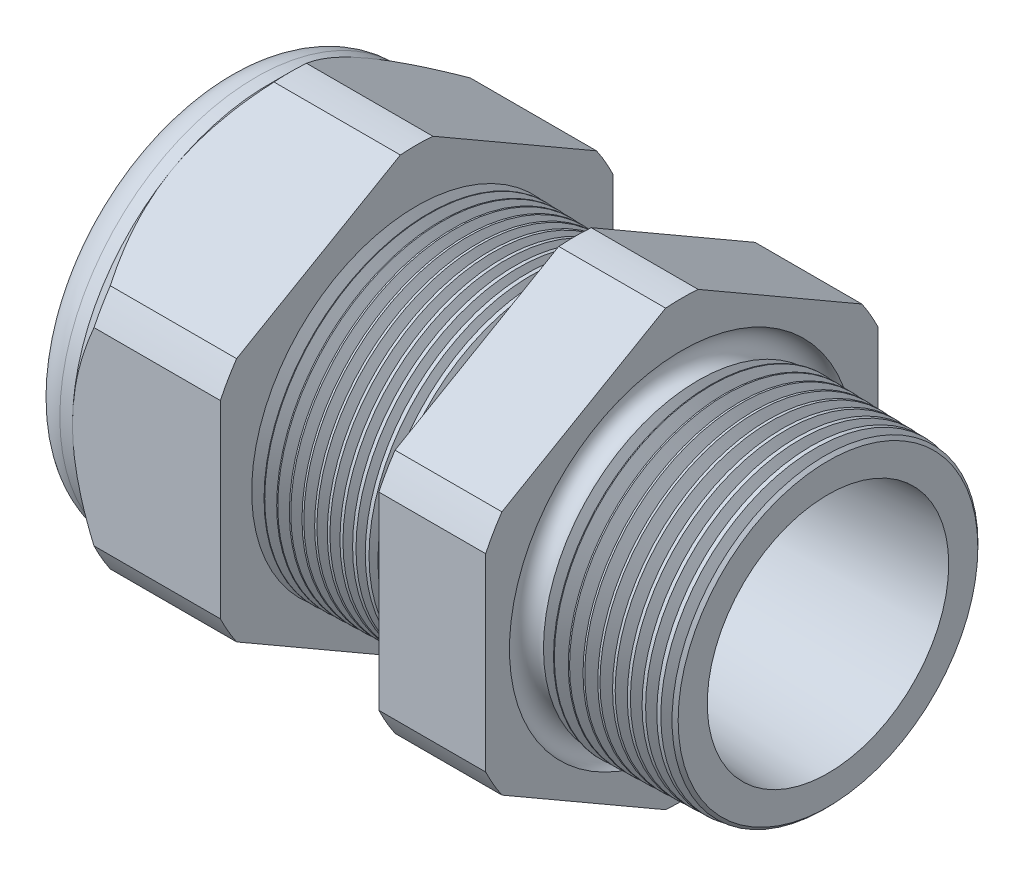
from build123d import *

# Parameters (mm, degrees)
SKETCH12_OUTSIDE_W = 65.136
SKETCH12_OUTSIDE_H = 65.136
CUT_EXTRUDE2_DEPTH = 35.03
FILLET4_R          = 2.032
SKETCH19_OUTSIDE_W = 40.13
SKETCH19_OUTSIDE_H = 42.756
SKETCH19_OUTSIDE_R = 11.938
CUT_EXTRUDE3_DEPTH = 1.999996
CUT_EXTRUDE3_DRAFT = -45
CHAMFER1_SIZE      = 0.260919487
CHAMFER1_SIZE2     = 0.254
SKETCH21_R         = 5.969
PLUG_DEPTH         = 6.35
SKETCH22_R         = 5.715
CUT_EXTRUDE4_DEPTH = 0.508
SKETCH27_R         = 2.54
PLUGHOLES_DEPTH    = 37.322
CIRPATTERN1_COUNT  = 3
LPATTERN1_COUNT    = 13
LPATTERN1_PITCH    = 0.762
LPATTERN2_COUNT    = 10
LPATTERN2_PITCH    = 0.889
SKETCH32_R         = 0.889


with BuildPart() as part:
    # Sketch10 → Revolve2 (revolve)
    with BuildSketch(Plane.XY, mode=Mode.PRIVATE) as revolve2_sk:
        Polygon((-35.814, 5.969), (-24.014, 5.969), (1.016, 7.345566383), (1.016, 9.377566383), (-7.874, 9.610359226), (-7.874, 23.876), (-14.374, 23.876), (-14.374, 9.780567716), (-24.014, 10.033), (-24.014, 23.876), (-33.014, 23.876), (-33.014, 11.938), (-35.814, 11.938), align=None)
    revolve(revolve2_sk.sketch.rotate(Axis((0, 0, 0), (-1, 0, 0)), 90), axis=Axis((0, 0, 0), (-1, 0, 0)))  # turned: the seam where the file's is

    # Sketch12 outside → Cut-Extrude2 (cut, through all)
    with BuildSketch(Plane.ZY.offset(33.014)):
        Rectangle(SKETCH12_OUTSIDE_W, SKETCH12_OUTSIDE_H)
        with BuildLine():
            Line((-0.98819228, 13.214281948), (-10.94980772, 7.462940592))
            ThreePointArc((-10.94980772, 7.462940592), (-11.47585851, 6.62559), (-11.938, 5.751341356))
            Line((-11.938, 5.751341356), (-11.938, -5.751341356))
            ThreePointArc((-11.938, -5.751341356), (-11.47585851, -6.62559), (-10.94980772, -7.462940592))
            Line((-10.94980772, -7.462940592), (-0.98819228, -13.214281948))
            ThreePointArc((-0.98819228, -13.214281948), (0, -13.25118), (0.98819228, -13.214281948))
            Line((0.98819228, -13.214281948), (10.94980772, -7.462940592))
            ThreePointArc((10.94980772, -7.462940592), (11.47585851, -6.62559), (11.938, -5.751341356))
            Line((11.938, -5.751341356), (11.938, 5.751341356))
            ThreePointArc((11.938, 5.751341356), (11.47585851, 6.62559), (10.94980772, 7.462940592))
            Line((10.94980772, 7.462940592), (0.98819228, 13.214281948))
            ThreePointArc((0.98819228, 13.214281948), (0, 13.25118), (-0.98819228, 13.214281948))
        make_face(mode=Mode.SUBTRACT)
    extrude(amount=-CUT_EXTRUDE2_DEPTH, mode=Mode.SUBTRACT)

    # Fillet4
    fillet4_edges = [part.edges().sort_by_distance(p)[0] for p in [
        (-35.814, 0, 11.938),
    ]]
    fillet(fillet4_edges, radius=FILLET4_R)


with BuildPart() as cut_extrude3_tool:
    # Sketch19 outside → Cut-Extrude3 (with draft: the straight prism first)
    with BuildSketch(Plane.ZY.offset(33.014)):
        Rectangle(SKETCH19_OUTSIDE_W, SKETCH19_OUTSIDE_H)
        Circle(SKETCH19_OUTSIDE_R, mode=Mode.SUBTRACT)
    extrude(amount=-CUT_EXTRUDE3_DEPTH)
    # Cut-Extrude3: the draft: its side faces are tilted about the plane it starts from
    cut_extrude3_sides = [cut_extrude3_tool.faces().sort_by_distance(p)[0] for p in [
        (-32.014002, -21.378, 0),
        (-32.014002, 0, 20.065),
        (-32.014002, 21.378, 0),
        (-32.014002, 0, -20.065),
        (-32.014002, 0, -11.938),
    ]]
    draft(cut_extrude3_sides, Plane.ZY.offset(33.014), CUT_EXTRUDE3_DRAFT)


with BuildPart() as part_1:
    add(part.part)

    # Cut-Extrude3: cut by cut_extrude3_tool
    add(cut_extrude3_tool.part, mode=Mode.SUBTRACT)

    # Chamfer1
    chamfer1_edges = [part_1.edges().sort_by_distance(p)[0] for p in [
        (1.016, 0, 9.377566383),
    ]]
    chamfer1_side = [part_1.faces().sort_by_distance(p)[0] for p in [
        (1.016, 0, 7.610804014),
    ]]
    chamfer(chamfer1_edges, length=CHAMFER1_SIZE, length2=CHAMFER1_SIZE2, reference=chamfer1_side[0])

    # Sketch29 → Cut-Revolve1 (revolve, cut)
    with BuildSketch(Plane.XY, mode=Mode.PRIVATE) as cut_revolve1_sk:
        Polygon((-24.014, 10.033), (-23.281016419, 10.013806149), (-23.664130572, 9.388620673), align=None)
    cut_revolve1 = revolve(cut_revolve1_sk.sketch.rotate(Axis((0, 0, 0), (-1, 0, 0)), 90), axis=Axis((0, 0, 0), (-1, 0, 0)), mode=Mode.SUBTRACT)  # turned: the seam where the file's is

    # LPattern1: Cut-Revolve1 ×13
    with Locations(*[(i * LPATTERN1_PITCH, 0, 0) for i in range(1, LPATTERN1_COUNT)]):
        add(cut_revolve1, mode=Mode.SUBTRACT)

    # Sketch30 → Cut-Revolve2 (revolve, cut)
    with BuildSketch(Plane.XY, mode=Mode.PRIVATE) as cut_revolve2_sk:
        Polygon((-7.874, 9.610359226), (-6.994419703, 9.587326605), (-7.454156686, 8.837104034), align=None)
    cut_revolve2 = revolve(cut_revolve2_sk.sketch.rotate(Axis((0, 0, 0), (-1, 0, 0)), 270), axis=Axis((0, 0, 0), (-1, 0, 0)), mode=Mode.SUBTRACT)  # turned: the seam where the file's is

    # LPattern2: Cut-Revolve2 ×10
    with Locations(*[(i * LPATTERN2_PITCH, 0, 0) for i in range(1, LPATTERN2_COUNT)]):
        add(cut_revolve2, mode=Mode.SUBTRACT)

    # Sketch32 → Cut-Revolve3 (revolve, cut)
    with BuildSketch(Plane.XY, mode=Mode.PRIVATE) as cut_revolve3_sk:
        with Locations((-7.747, 9.610359226)):
            Circle(SKETCH32_R)
    revolve(cut_revolve3_sk.sketch.rotate(Axis((0, 0, 0), (-1, 0, 0)), 270), axis=Axis((0, 0, 0), (-1, 0, 0)), mode=Mode.SUBTRACT)  # turned: the seam where the file's is


with BuildPart() as body_2:
    # Sketch21 → plug (new body)
    with BuildSketch(Plane.ZY.offset(35.814)):
        Circle(SKETCH21_R)
    extrude(amount=-PLUG_DEPTH)

    # Sketch22 → Cut-Extrude4 (cut)
    with BuildSketch(Plane.ZY.offset(35.814)):
        Circle(SKETCH22_R)
    extrude(amount=-CUT_EXTRUDE4_DEPTH, mode=Mode.SUBTRACT)

    # Sketch27 → plugholes (cut, through all)
    with BuildSketch(Plane.ZY.offset(35.306)):
        with Locations((-3.16484, 0)):
            Circle(SKETCH27_R)
    plugholes = extrude(amount=-PLUGHOLES_DEPTH, mode=Mode.SUBTRACT)

    # CirPattern1: plugholes ×3 about axis
    cirpattern1_axis = Axis((0, 0, 0), (1, 0, 0))
    for i in range(1, CIRPATTERN1_COUNT):
        add(plugholes.rotate(cirpattern1_axis, i * 360 / CIRPATTERN1_COUNT), mode=Mode.SUBTRACT)


solid = Compound([part_1.part, body_2.part])
